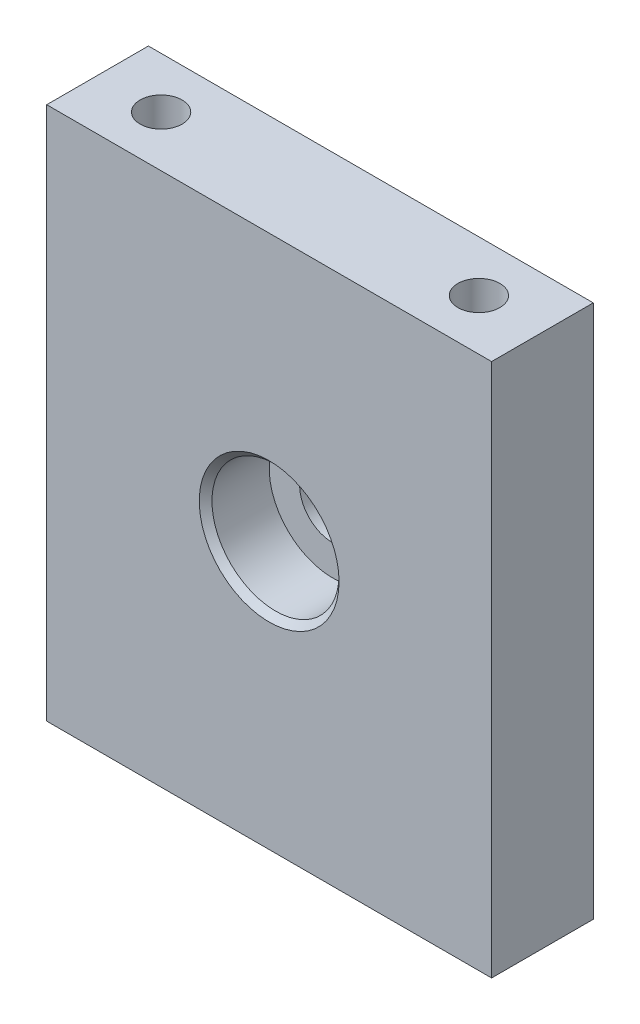
from build123d import *

# Parameters (mm, degrees)
SKETCH_1_W          = 35
SKETCH_1_H          = 42
EXTRUDE_1_DEPTH     = 4
SKETCH_4_R          = 10
EXTRUDE_2_DEPTH     = 3.5
CUT_EXTRUDE_2_DEPTH = 2
SKETCH_6_R          = 2.6
CUT_EXTRUDE_3_DEPTH = 12.5
SKETCH_7_R          = 5
CUT_EXTRUDE_4_DEPTH = 5
CHAMFER_1_SIZE      = 0.5
CHAMFER_2_SIZE      = 0.5
CHAMFER_3_SIZE      = 1
HOLE_WIZARD_M4_1_D  = 3.3


with BuildPart() as part:
    # 草图1 → 凸台-拉伸1 (new body, symmetric)
    with BuildSketch(Plane.XY):
        Rectangle(SKETCH_1_W, SKETCH_1_H)
    extrude(amount=EXTRUDE_1_DEPTH, both=True)

    # 草图4 → 凸台-拉伸2 (add)
    with BuildSketch(Plane(origin=(0, 0, -4), x_dir=(-1, 0, 0), z_dir=(0, 0, -1))):
        Circle(SKETCH_4_R)
        with BuildLine():
            Line((-5, 6), (5, 6))
            ThreePointArc((5, 6), (5.707106781, 5.707106781), (6, 5))
            Line((6, 5), (6, -5))
            ThreePointArc((6, -5), (5.707106781, -5.707106781), (5, -6))
            Line((5, -6), (-5, -6))
            ThreePointArc((-5, -6), (-5.707106781, -5.707106781), (-6, -5))
            Line((-6, -5), (-6, 5))
            ThreePointArc((-6, 5), (-5.707106781, 5.707106781), (-5, 6))
        make_face(mode=Mode.SUBTRACT)
    extrude(amount=EXTRUDE_2_DEPTH)

    # 草图5 → 切除-拉伸2 (cut)
    with BuildSketch(Plane(origin=(0, 0, -4), x_dir=(-1, 0, 0), z_dir=(0, 0, -1))):
        with BuildLine():
            Line((6, -5), (6, 5))
            ThreePointArc((6, 5), (5.707106781, 5.707106781), (5, 6))
            Line((5, 6), (-5, 6))
            ThreePointArc((-5, 6), (-5.707106781, 5.707106781), (-6, 5))
            Line((-6, 5), (-6, -5))
            ThreePointArc((-6, -5), (-5.707106781, -5.707106781), (-5, -6))
            Line((-5, -6), (5, -6))
            ThreePointArc((5, -6), (5.707106781, -5.707106781), (6, -5))
        make_face()
    extrude(amount=-CUT_EXTRUDE_2_DEPTH, mode=Mode.SUBTRACT)

    # 草图6 → 切除-拉伸3 (cut, through all)
    with BuildSketch(Plane.XY.offset(4)):
        Circle(SKETCH_6_R)
    extrude(amount=-CUT_EXTRUDE_3_DEPTH, mode=Mode.SUBTRACT)

    # 草图7 → 切除-拉伸4 (cut)
    with BuildSketch(Plane.XY.offset(4)):
        Circle(SKETCH_7_R)
    extrude(amount=-CUT_EXTRUDE_4_DEPTH, mode=Mode.SUBTRACT)

    # 倒角1
    chamfer_1_edges = [part.edges().sort_by_distance(p)[0] for p in [
        (-5.707106781, 5.707106781, -7.5),
        (0, 6, -7.5),
        (5.707106781, 5.707106781, -7.5),
        (6, 0, -7.5),
        (5.707106781, -5.707106781, -7.5),
        (0, -6, -7.5),
        (-5.707106781, -5.707106781, -7.5),
        (-6, 0, -7.5),
    ]]
    chamfer(chamfer_1_edges, length=CHAMFER_1_SIZE)

    # 倒角2
    chamfer_2_edges = [part.edges().sort_by_distance(p)[0] for p in [
        (-5, 0, 4),
    ]]
    chamfer(chamfer_2_edges, length=CHAMFER_2_SIZE)

    # 倒角3
    chamfer_3_edges = [part.edges().sort_by_distance(p)[0] for p in [
        (10, 0, -4),
    ]]
    chamfer(chamfer_3_edges, length=CHAMFER_3_SIZE)

    # M4 螺纹孔1 (through all)
    with Locations(Plane(origin=(0, 21, 0), x_dir=(1, 0, 0), z_dir=(0, 1, 0))):
        with Locations((-12.5, 0), (12.5, 0)):
            Hole(HOLE_WIZARD_M4_1_D / 2)


solid = part.part
